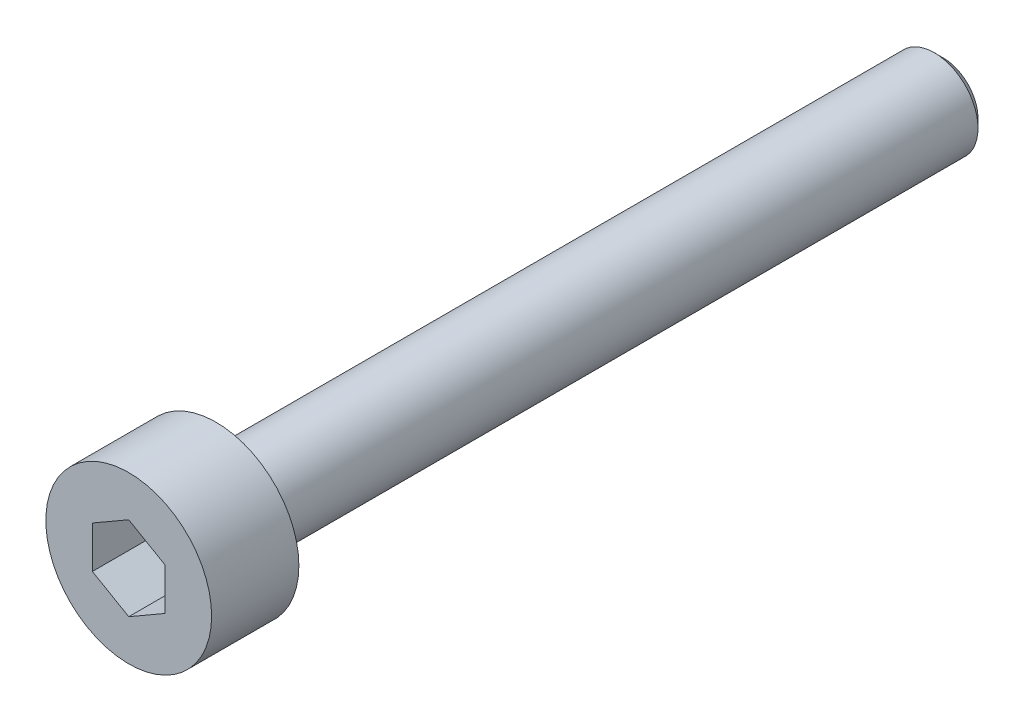
from build123d import *

# Parameters (mm, degrees)
SKETCH1_R           = 2.85
BOSS_EXTRUDE1_DEPTH = 3
SKETCH2_R           = 1.5
BOSS_EXTRUDE2_DEPTH = 25
CHAMFER1_SIZE       = 0.3
CUT_EXTRUDE1_DEPTH  = 2


with BuildPart() as part:
    # Sketch1 → Boss-Extrude1 (new body)
    with BuildSketch(Plane.XY):
        Circle(SKETCH1_R)
    extrude(amount=BOSS_EXTRUDE1_DEPTH)

    # Sketch2 → Boss-Extrude2 (add)
    with BuildSketch(Plane(origin=(0, 0, 0), x_dir=(-1, 0, 0), z_dir=(0, 0, -1))):
        Circle(SKETCH2_R)
    extrude(amount=BOSS_EXTRUDE2_DEPTH)

    # Chamfer1
    chamfer1_edges = [part.edges().sort_by_distance(p)[0] for p in [
        (1.5, 0, -25),
    ]]
    chamfer(chamfer1_edges, length=CHAMFER1_SIZE)

    # Sketch3 → Cut-Extrude1 (cut)
    with BuildSketch(Plane.XY.offset(3)):
        Polygon((0, 1.443375673), (-1.25, 0.721687836), (-1.25, -0.721687836), (0, -1.443375673), (1.25, -0.721687836), (1.25, 0.721687836), align=None)
    extrude(amount=-CUT_EXTRUDE1_DEPTH, mode=Mode.SUBTRACT)


solid = part.part
